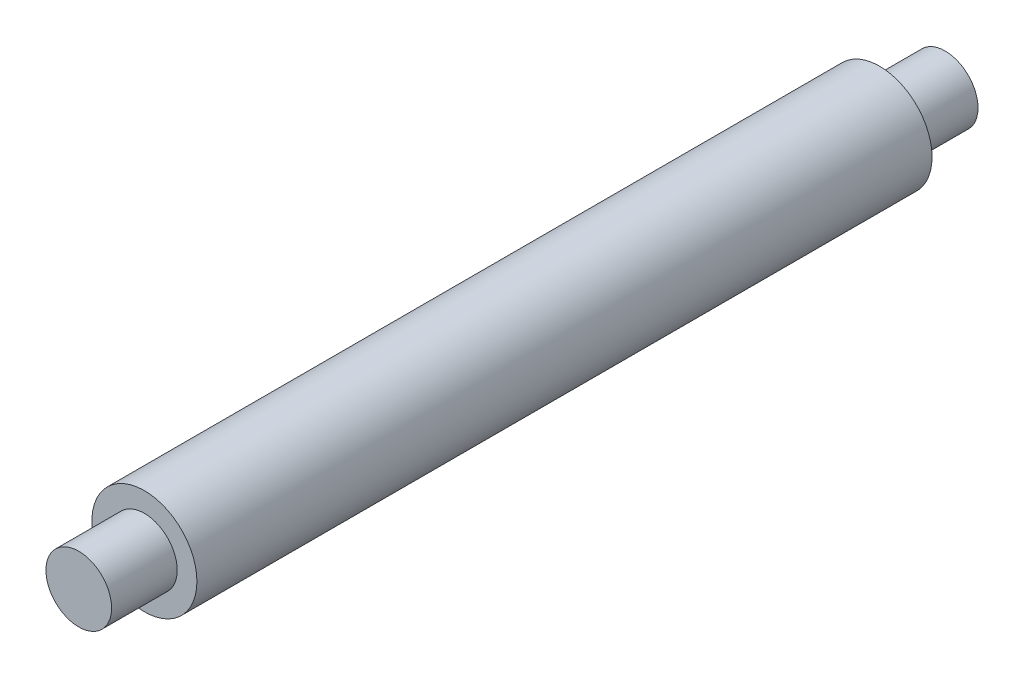
from build123d import *

# Parameters (mm, degrees)
CROQUIS1_R              = 4
SALIENTE_EXTRUIR1_DEPTH = 56
CROQUIS2_R              = 2.5
SALIENTE_EXTRUIR2_DEPTH = 5
CROQUIS3_R              = 2.5
SALIENTE_EXTRUIR3_DEPTH = 5


with BuildPart() as part:
    # Croquis1 → Saliente-Extruir1 (new body)
    with BuildSketch(Plane.XY):
        Circle(CROQUIS1_R)
    extrude(amount=SALIENTE_EXTRUIR1_DEPTH)

    # Croquis2 → Saliente-Extruir2 (add)
    with BuildSketch(Plane.XY.offset(56)):
        Circle(CROQUIS2_R)
    extrude(amount=SALIENTE_EXTRUIR2_DEPTH)

    # Croquis3 → Saliente-Extruir3 (add)
    with BuildSketch(Plane(origin=(0, 0, 0), x_dir=(-1, 0, 0), z_dir=(0, 0, -1))):
        Circle(CROQUIS3_R)
    extrude(amount=SALIENTE_EXTRUIR3_DEPTH)


solid = part.part
